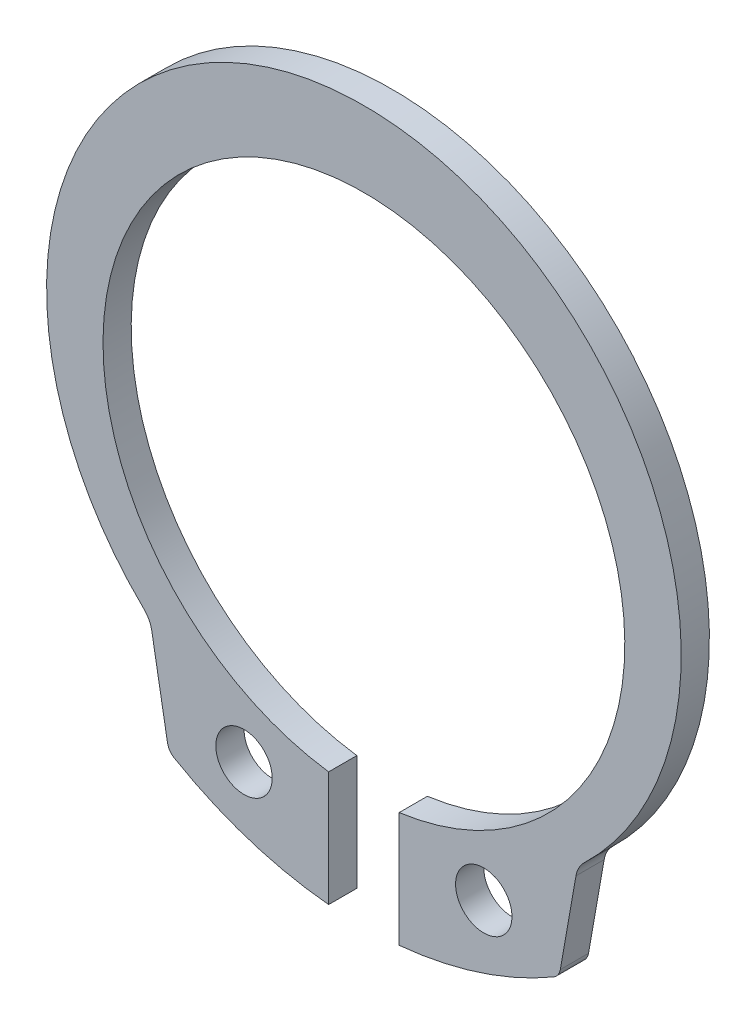
from build123d import *

# Parameters (mm, degrees)
SKETCH1_R  = 1
BODY_DEPTH = 1
FILLET1_R  = 0.5
FILLET2_R  = 1


with BuildPart() as part:
    # Sketch1 → Body (new body)
    with BuildSketch(Plane.XY):
        with BuildLine():
            Line((-1.25, -9.83515139), (-1.25, -13.911129106))
            ThreePointArc((-1.25, -13.911129106), (-4.193699318, -13.291524711), (-6.922858868, -12.026232874))
            Line((-6.922858868, -12.026232874), (-7.577141132, -8.315613763))
            ThreePointArc((-7.577141132, -8.315613763), (0, 11.25), (7.577141132, -8.315613763))
            Line((7.577141132, -8.315613763), (6.922858868, -12.026232874))
            ThreePointArc((6.922858868, -12.026232874), (4.193699318, -13.291524711), (1.25, -13.911129106))
            Line((1.25, -13.911129106), (1.25, -9.83515139))
            ThreePointArc((1.25, -9.83515139), (0, 8.58), (-1.25, -9.83515139))
        make_face()
        with Locations((4.25, -11.032311518)):
            Circle(SKETCH1_R, mode=Mode.SUBTRACT)
        with Locations((-4.25, -11.032311518)):
            Circle(SKETCH1_R, mode=Mode.SUBTRACT)
    extrude(amount=-BODY_DEPTH)

    # Fillet1
    fillet1_edges = [part.edges().sort_by_distance(p)[0] for p in [
        (-6.922858868, -12.026232874, -0.5),
        (6.922858868, -12.026232874, -0.5),
    ]]
    fillet(fillet1_edges, radius=FILLET1_R)

    # Fillet2
    fillet2_edges = [part.edges().sort_by_distance(p)[0] for p in [
        (-7.577141132, -8.315613763, -0.5),
        (7.577141132, -8.315613763, -0.5),
    ]]
    fillet(fillet2_edges, radius=FILLET2_R)


solid = part.part
